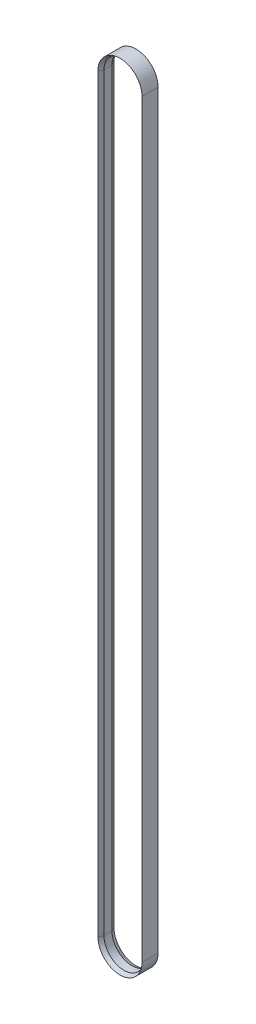
from build123d import *


with BuildPart() as part:
    # Sweep1: sweep along a path in Sketch2
    with BuildLine(Plane.XY) as sweep1_path:
        Line((25, 0), (25, -935.5))
        ThreePointArc((25, -935.5), (0, -960.5), (-25, -935.5))
        Line((-25, -935.5), (-25, 0))
        ThreePointArc((-25, 0), (0, 25), (25, 0))
    # Sketch3 → Sweep1 (sweep)
    with BuildSketch(Plane(origin=(0, 0, 0), x_dir=(1, 0, 0), z_dir=(0, 1, 0))):
        Polygon((25, 5), (25, -5), (27.5, -10), (27.5, 10), align=None)
    sweep(path=sweep1_path.line)


solid = part.part
